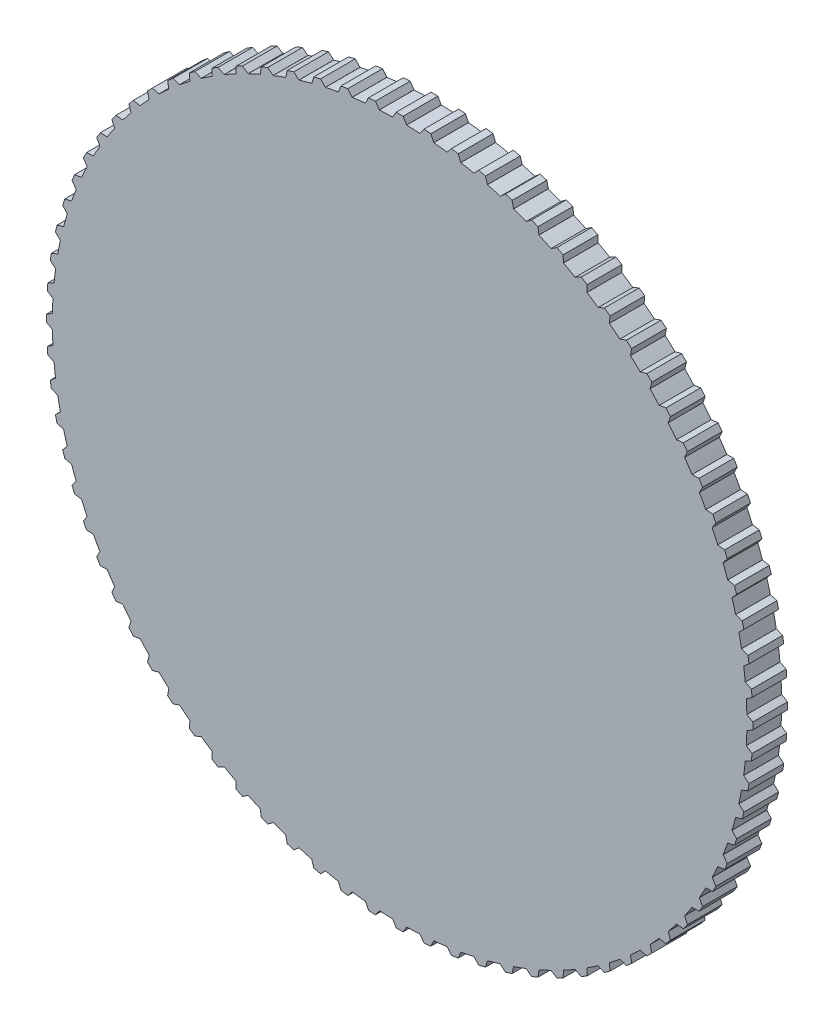
from build123d import *

# Parameters (mm, degrees)
BOSS_EXTRUDE1_DEPTH = 10


with BuildPart() as part:
    # Sketch1 → Boss-Extrude1 (new body)
    with BuildSketch(Plane.XY):
        with BuildLine():
            Line((0, 101.7), (1, 101.7))
            Line((1, 101.7), (2, 100))
            Line((2, 100), (1.99960012, 99.980005998))
            ThreePointArc((1.99960012, 99.980005998), (3.925981576, 99.922903624), (5.850904841, 99.828687823))
            Line((5.850904841, 99.828687823), (5.852074905, 99.848651565))
            Line((5.852074905, 99.848651565), (6.982372702, 101.464951936))
            Line((6.982372702, 101.464951936), (7.979290036, 101.386492841))
            Line((7.979290036, 101.386492841), (8.976207369, 101.308033745))
            Line((8.976207369, 101.308033745), (9.83974424, 99.534815182))
            Line((9.83974424, 99.534815182), (9.837776882, 99.514914189))
            ThreePointArc((9.837776882, 99.514914189), (11.753739746, 99.306845695), (13.665337029, 99.061892592))
            Line((13.665337029, 99.061892592), (13.668069823, 99.08170299))
            Line((13.668069823, 99.08170299), (14.921696754, 100.604338704))
            Line((14.921696754, 100.604338704), (15.909385095, 100.447904239))
            Line((15.909385095, 100.447904239), (16.897073435, 100.291469773))
            Line((16.897073435, 100.291469773), (17.618823185, 98.455965129))
            Line((17.618823185, 98.455965129), (17.615300477, 98.436279842))
            ThreePointArc((17.615300477, 98.436279842), (19.509032202, 98.07852804), (21.395517869, 97.684347851))
            Line((21.395517869, 97.684347851), (21.399796545, 97.703882767))
            Line((21.399796545, 97.703882767), (22.769023584, 99.123466268))
            Line((22.769023584, 99.123466268), (23.741393504, 98.890020904))
            Line((23.741393504, 98.890020904), (24.713763425, 98.656575541))
            Line((24.713763425, 98.656575541), (25.289276226, 96.770101312))
            Line((25.289276226, 96.770101312), (25.284219888, 96.750753096))
            ThreePointArc((25.284219888, 96.750753096), (27.144044987, 96.245523645), (28.993788227, 95.704546623))
            Line((28.993788227, 95.704546623), (28.999586405, 95.723685618))
            Line((28.999586405, 95.723685618), (30.475971812, 97.031464702))
            Line((30.475971812, 97.031464702), (31.427028328, 96.722447707))
            Line((31.427028328, 96.722447707), (32.378084844, 96.413430713))
            Line((32.378084844, 96.413430713), (32.80381247, 94.487617641))
            Line((32.80381247, 94.487617641), (32.797253675, 94.468725785))
            ThreePointArc((32.797253675, 94.468725785), (34.611705708, 93.819133592), (36.413302239, 93.134695039))
            Line((36.413302239, 93.134695039), (36.420584171, 93.153320116))
            Line((36.420584171, 93.153320116), (37.995025539, 94.341231889))
            Line((37.995025539, 94.341231889), (38.918905072, 93.958548456))
            Line((38.918905072, 93.958548456), (39.842784604, 93.575865024))
            Line((39.842784604, 93.575865024), (40.116102302, 91.622586386))
            Line((40.116102302, 91.622586386), (40.108081487, 91.604267365))
            ThreePointArc((40.108081487, 91.604267365), (41.865973754, 90.814317383), (43.608316134, 89.99063709))
            Line((43.608316134, 89.99063709), (43.617036926, 90.008633418))
            Line((43.617036926, 90.008633418), (45.279827299, 91.06935401))
            Line((45.279827299, 91.06935401), (46.170833824, 90.61536351))
            Line((46.170833824, 90.61536351), (47.061840348, 90.16137301))
            Line((47.061840348, 90.16137301), (47.181063022, 88.192671419))
            Line((47.181063022, 88.192671419), (47.17162964, 88.175038175))
            ThreePointArc((47.17162964, 88.175038175), (48.86212415, 87.249600707), (50.534470259, 86.291756939))
            Line((50.534470259, 86.291756939), (50.544576143, 86.309013565))
            Line((50.544576143, 86.309013565), (52.285463867, 87.23600328))
            Line((52.285463867, 87.23600328), (53.138104032, 86.713504715))
            Line((53.138104032, 86.713504715), (53.990744196, 86.19100615))
            Line((53.990744196, 86.19100615), (53.9551368, 84.219019306))
            Line((53.9551368, 84.219019306), (53.944349009, 84.202180554))
            ThreePointArc((53.944349009, 84.202180554), (55.557023302, 83.14696123), (57.149062571, 82.060859411))
            Line((57.149062571, 82.060859411), (57.16049124, 82.077269942))
            Line((57.16049124, 82.077269942), (58.968743164, 82.86481358))
            Line((58.968743164, 82.86481358), (59.777760158, 82.277028328))
            Line((59.777760158, 82.277028328), (60.586777153, 81.689243076))
            Line((60.586777153, 81.689243076), (60.396559218, 79.726128933))
            Line((60.396559218, 79.726128933), (60.384483529, 79.710188489))
            ThreePointArc((60.384483529, 79.710188489), (61.909394931, 78.531693088), (63.411311907, 77.324029397))
            Line((63.411311907, 77.324029397), (63.423992902, 77.339492657))
            Line((63.423992902, 77.339492657), (65.28846055, 77.98273475))
            Line((65.28846055, 77.98273475), (66.048866515, 77.333286702))
            Line((66.048866515, 77.333286702), (66.809272481, 76.683838653))
            Line((66.809272481, 76.683838653), (66.465616764, 74.741700463))
            Line((66.465616764, 74.741700463), (66.452327627, 74.726756606))
            ThreePointArc((66.452327627, 74.726756606), (67.880074553, 73.432250944), (69.28260942, 72.110471029))
            Line((69.28260942, 72.110471029), (69.296464556, 72.124891681))
            Line((69.296464556, 72.124891681), (71.205652865, 72.619866428))
            Line((71.205652865, 72.619866428), (71.912759647, 71.912759647))
            Line((71.912759647, 71.912759647), (72.619866428, 71.205652865))
            Line((72.619866428, 71.205652865), (72.124891681, 69.296464556))
            Line((72.124891681, 69.296464556), (72.110471029, 69.28260942))
            ThreePointArc((72.110471029, 69.28260942), (73.432250944, 67.880074553), (74.726756606, 66.452327627))
            Line((74.726756606, 66.452327627), (74.741700463, 66.465616764))
            Line((74.741700463, 66.465616764), (76.683838653, 66.809272481))
            Line((76.683838653, 66.809272481), (77.333286702, 66.048866515))
            Line((77.333286702, 66.048866515), (77.98273475, 65.28846055))
            Line((77.98273475, 65.28846055), (77.339492657, 63.423992902))
            Line((77.339492657, 63.423992902), (77.324029397, 63.411311907))
            ThreePointArc((77.324029397, 63.411311907), (78.531693088, 61.909394931), (79.710188489, 60.384483529))
            Line((79.710188489, 60.384483529), (79.726128933, 60.396559218))
            Line((79.726128933, 60.396559218), (81.689243076, 60.586777153))
            Line((81.689243076, 60.586777153), (82.277028328, 59.777760158))
            Line((82.277028328, 59.777760158), (82.86481358, 58.968743164))
            Line((82.86481358, 58.968743164), (82.077269942, 57.160491241))
            Line((82.077269942, 57.160491241), (82.060859411, 57.149062571))
            ThreePointArc((82.060859411, 57.149062571), (83.14696123, 55.557023302), (84.202180554, 53.944349009))
            Line((84.202180554, 53.944349009), (84.219019306, 53.9551368))
            Line((84.219019306, 53.9551368), (86.19100615, 53.990744196))
            Line((86.19100615, 53.990744196), (86.713504715, 53.138104032))
            Line((86.713504715, 53.138104032), (87.23600328, 52.285463867))
            Line((87.23600328, 52.285463867), (86.309013565, 50.544576143))
            Line((86.309013565, 50.544576143), (86.291756939, 50.534470259))
            ThreePointArc((86.291756939, 50.534470259), (87.249600707, 48.86212415), (88.175038175, 47.17162964))
            Line((88.175038175, 47.17162964), (88.192671419, 47.181063022))
            Line((88.192671419, 47.181063022), (90.16137301, 47.061840348))
            Line((90.16137301, 47.061840348), (90.61536351, 46.170833824))
            Line((90.61536351, 46.170833824), (91.06935401, 45.279827299))
            Line((91.06935401, 45.279827299), (90.008633418, 43.617036926))
            Line((90.008633418, 43.617036926), (89.99063709, 43.608316134))
            ThreePointArc((89.99063709, 43.608316134), (90.814317383, 41.865973754), (91.604267365, 40.108081487))
            Line((91.604267365, 40.108081487), (91.622586386, 40.116102302))
            Line((91.622586386, 40.116102302), (93.575865024, 39.842784604))
            Line((93.575865024, 39.842784604), (93.958548456, 38.918905072))
            Line((93.958548456, 38.918905072), (94.341231889, 37.995025539))
            Line((94.341231889, 37.995025539), (93.153320116, 36.420584171))
            Line((93.153320116, 36.420584171), (93.134695039, 36.413302239))
            ThreePointArc((93.134695039, 36.413302239), (93.819133592, 34.611705708), (94.468725785, 32.797253675))
            Line((94.468725785, 32.797253675), (94.487617641, 32.80381247))
            Line((94.487617641, 32.80381247), (96.413430713, 32.378084844))
            Line((96.413430713, 32.378084844), (96.722447707, 31.427028328))
            Line((96.722447707, 31.427028328), (97.031464702, 30.475971812))
            Line((97.031464702, 30.475971812), (95.723685618, 28.999586405))
            Line((95.723685618, 28.999586405), (95.704546623, 28.993788227))
            ThreePointArc((95.704546623, 28.993788227), (96.245523645, 27.144044987), (96.750753096, 25.284219888))
            Line((96.750753096, 25.284219888), (96.770101312, 25.289276226))
            Line((96.770101312, 25.289276226), (98.656575541, 24.713763425))
            Line((98.656575541, 24.713763425), (98.890020904, 23.741393504))
            Line((98.890020904, 23.741393504), (99.123466268, 22.769023584))
            Line((99.123466268, 22.769023584), (97.703882767, 21.399796545))
            Line((97.703882767, 21.399796545), (97.684347851, 21.395517869))
            ThreePointArc((97.684347851, 21.395517869), (98.07852804, 19.509032202), (98.436279842, 17.615300477))
            Line((98.436279842, 17.615300477), (98.455965129, 17.618823185))
            Line((98.455965129, 17.618823185), (100.291469773, 16.897073435))
            Line((100.291469773, 16.897073435), (100.447904239, 15.909385095))
            Line((100.447904239, 15.909385095), (100.604338704, 14.921696754))
            Line((100.604338704, 14.921696754), (99.08170299, 13.668069823))
            Line((99.08170299, 13.668069823), (99.061892592, 13.665337029))
            ThreePointArc((99.061892592, 13.665337029), (99.306845695, 11.753739746), (99.514914189, 9.837776882))
            Line((99.514914189, 9.837776882), (99.534815182, 9.83974424))
            Line((99.534815182, 9.83974424), (101.308033745, 8.976207369))
            Line((101.308033745, 8.976207369), (101.386492841, 7.979290036))
            Line((101.386492841, 7.979290036), (101.464951936, 6.982372702))
            Line((101.464951936, 6.982372702), (99.848651565, 5.852074905))
            Line((99.848651565, 5.852074905), (99.828687823, 5.850904841))
            ThreePointArc((99.828687823, 5.850904841), (99.922903624, 3.925981576), (99.980005998, 1.99960012))
            Line((99.980005998, 1.99960012), (100, 2))
            Line((100, 2), (101.7, 1))
            Line((101.7, 1), (101.7, 0))
            Line((101.7, 0), (101.7, -1))
            Line((101.7, -1), (100, -2))
            Line((100, -2), (99.980005998, -1.99960012))
            ThreePointArc((99.980005998, -1.99960012), (99.922903624, -3.925981576), (99.828687823, -5.850904841))
            Line((99.828687823, -5.850904841), (99.848651565, -5.852074905))
            Line((99.848651565, -5.852074905), (101.464951936, -6.982372702))
            Line((101.464951936, -6.982372702), (101.386492841, -7.979290036))
            Line((101.386492841, -7.979290036), (101.308033745, -8.976207369))
            Line((101.308033745, -8.976207369), (99.534815182, -9.83974424))
            Line((99.534815182, -9.83974424), (99.514914189, -9.837776882))
            ThreePointArc((99.514914189, -9.837776882), (99.306845695, -11.753739746), (99.061892592, -13.665337029))
            Line((99.061892592, -13.665337029), (99.08170299, -13.668069823))
            Line((99.08170299, -13.668069823), (100.604338704, -14.921696754))
            Line((100.604338704, -14.921696754), (100.447904239, -15.909385095))
            Line((100.447904239, -15.909385095), (100.291469773, -16.897073435))
            Line((100.291469773, -16.897073435), (98.455965129, -17.618823185))
            Line((98.455965129, -17.618823185), (98.436279842, -17.615300477))
            ThreePointArc((98.436279842, -17.615300477), (98.07852804, -19.509032202), (97.684347851, -21.395517869))
            Line((97.684347851, -21.395517869), (97.703882767, -21.399796545))
            Line((97.703882767, -21.399796545), (99.123466268, -22.769023584))
            Line((99.123466268, -22.769023584), (98.890020904, -23.741393504))
            Line((98.890020904, -23.741393504), (98.656575541, -24.713763425))
            Line((98.656575541, -24.713763425), (96.770101312, -25.289276226))
            Line((96.770101312, -25.289276226), (96.750753096, -25.284219888))
            ThreePointArc((96.750753096, -25.284219888), (96.245523645, -27.144044987), (95.704546623, -28.993788227))
            Line((95.704546623, -28.993788227), (95.723685618, -28.999586405))
            Line((95.723685618, -28.999586405), (97.031464702, -30.475971812))
            Line((97.031464702, -30.475971812), (96.722447707, -31.427028328))
            Line((96.722447707, -31.427028328), (96.413430713, -32.378084844))
            Line((96.413430713, -32.378084844), (94.487617641, -32.80381247))
            Line((94.487617641, -32.80381247), (94.468725785, -32.797253675))
            ThreePointArc((94.468725785, -32.797253675), (93.819133592, -34.611705708), (93.134695039, -36.413302239))
            Line((93.134695039, -36.413302239), (93.153320116, -36.420584171))
            Line((93.153320116, -36.420584171), (94.341231889, -37.995025539))
            Line((94.341231889, -37.995025539), (93.958548456, -38.918905072))
            Line((93.958548456, -38.918905072), (93.575865024, -39.842784604))
            Line((93.575865024, -39.842784604), (91.622586386, -40.116102302))
            Line((91.622586386, -40.116102302), (91.604267365, -40.108081487))
            ThreePointArc((91.604267365, -40.108081487), (90.814317383, -41.865973754), (89.99063709, -43.608316134))
            Line((89.99063709, -43.608316134), (90.008633418, -43.617036926))
            Line((90.008633418, -43.617036926), (91.06935401, -45.279827299))
            Line((91.06935401, -45.279827299), (90.61536351, -46.170833824))
            Line((90.61536351, -46.170833824), (90.16137301, -47.061840348))
            Line((90.16137301, -47.061840348), (88.192671419, -47.181063022))
            Line((88.192671419, -47.181063022), (88.175038175, -47.17162964))
            ThreePointArc((88.175038175, -47.17162964), (87.249600707, -48.86212415), (86.291756939, -50.534470259))
            Line((86.291756939, -50.534470259), (86.309013565, -50.544576143))
            Line((86.309013565, -50.544576143), (87.23600328, -52.285463867))
            Line((87.23600328, -52.285463867), (86.713504715, -53.138104032))
            Line((86.713504715, -53.138104032), (86.19100615, -53.990744196))
            Line((86.19100615, -53.990744196), (84.219019306, -53.9551368))
            Line((84.219019306, -53.9551368), (84.202180554, -53.944349009))
            ThreePointArc((84.202180554, -53.944349009), (83.14696123, -55.557023302), (82.060859411, -57.149062571))
            Line((82.060859411, -57.149062571), (82.077269942, -57.16049124))
            Line((82.077269942, -57.16049124), (82.86481358, -58.968743164))
            Line((82.86481358, -58.968743164), (82.277028328, -59.777760158))
            Line((82.277028328, -59.777760158), (81.689243076, -60.586777153))
            Line((81.689243076, -60.586777153), (79.726128933, -60.396559218))
            Line((79.726128933, -60.396559218), (79.710188489, -60.384483529))
            ThreePointArc((79.710188489, -60.384483529), (78.531693088, -61.909394931), (77.324029397, -63.411311907))
            Line((77.324029397, -63.411311907), (77.339492657, -63.423992902))
            Line((77.339492657, -63.423992902), (77.98273475, -65.28846055))
            Line((77.98273475, -65.28846055), (77.333286702, -66.048866515))
            Line((77.333286702, -66.048866515), (76.683838653, -66.809272481))
            Line((76.683838653, -66.809272481), (74.741700463, -66.465616764))
            Line((74.741700463, -66.465616764), (74.726756606, -66.452327627))
            ThreePointArc((74.726756606, -66.452327627), (73.432250944, -67.880074553), (72.110471029, -69.28260942))
            Line((72.110471029, -69.28260942), (72.124891681, -69.296464556))
            Line((72.124891681, -69.296464556), (72.619866428, -71.205652865))
            Line((72.619866428, -71.205652865), (71.912759647, -71.912759647))
            Line((71.912759647, -71.912759647), (71.205652865, -72.619866428))
            Line((71.205652865, -72.619866428), (69.296464556, -72.124891681))
            Line((69.296464556, -72.124891681), (69.28260942, -72.110471029))
            ThreePointArc((69.28260942, -72.110471029), (67.880074553, -73.432250944), (66.452327627, -74.726756606))
            Line((66.452327627, -74.726756606), (66.465616764, -74.741700463))
            Line((66.465616764, -74.741700463), (66.809272481, -76.683838653))
            Line((66.809272481, -76.683838653), (66.048866515, -77.333286702))
            Line((66.048866515, -77.333286702), (65.28846055, -77.98273475))
            Line((65.28846055, -77.98273475), (63.423992902, -77.339492657))
            Line((63.423992902, -77.339492657), (63.411311907, -77.324029397))
            ThreePointArc((63.411311907, -77.324029397), (61.909394931, -78.531693088), (60.384483529, -79.710188489))
            Line((60.384483529, -79.710188489), (60.396559218, -79.726128933))
            Line((60.396559218, -79.726128933), (60.586777153, -81.689243076))
            Line((60.586777153, -81.689243076), (59.777760158, -82.277028328))
            Line((59.777760158, -82.277028328), (58.968743164, -82.86481358))
            Line((58.968743164, -82.86481358), (57.16049124, -82.077269942))
            Line((57.16049124, -82.077269942), (57.149062571, -82.060859411))
            ThreePointArc((57.149062571, -82.060859411), (55.557023302, -83.14696123), (53.944349009, -84.202180554))
            Line((53.944349009, -84.202180554), (53.9551368, -84.219019306))
            Line((53.9551368, -84.219019306), (53.990744196, -86.19100615))
            Line((53.990744196, -86.19100615), (53.138104032, -86.713504715))
            Line((53.138104032, -86.713504715), (52.285463867, -87.23600328))
            Line((52.285463867, -87.23600328), (50.544576143, -86.309013565))
            Line((50.544576143, -86.309013565), (50.534470259, -86.291756939))
            ThreePointArc((50.534470259, -86.291756939), (48.86212415, -87.249600707), (47.17162964, -88.175038175))
            Line((47.17162964, -88.175038175), (47.181063022, -88.192671419))
            Line((47.181063022, -88.192671419), (47.061840348, -90.16137301))
            Line((47.061840348, -90.16137301), (46.170833824, -90.61536351))
            Line((46.170833824, -90.61536351), (45.279827299, -91.06935401))
            Line((45.279827299, -91.06935401), (43.617036926, -90.008633418))
            Line((43.617036926, -90.008633418), (43.608316134, -89.99063709))
            ThreePointArc((43.608316134, -89.99063709), (41.865973754, -90.814317383), (40.108081487, -91.604267365))
            Line((40.108081487, -91.604267365), (40.116102302, -91.622586386))
            Line((40.116102302, -91.622586386), (39.842784604, -93.575865024))
            Line((39.842784604, -93.575865024), (38.918905072, -93.958548456))
            Line((38.918905072, -93.958548456), (37.995025539, -94.341231889))
            Line((37.995025539, -94.341231889), (36.420584171, -93.153320116))
            Line((36.420584171, -93.153320116), (36.413302239, -93.134695039))
            ThreePointArc((36.413302239, -93.134695039), (34.611705708, -93.819133592), (32.797253675, -94.468725785))
            Line((32.797253675, -94.468725785), (32.80381247, -94.487617641))
            Line((32.80381247, -94.487617641), (32.378084844, -96.413430713))
            Line((32.378084844, -96.413430713), (31.427028328, -96.722447707))
            Line((31.427028328, -96.722447707), (30.475971812, -97.031464702))
            Line((30.475971812, -97.031464702), (28.999586405, -95.723685618))
            Line((28.999586405, -95.723685618), (28.993788227, -95.704546623))
            ThreePointArc((28.993788227, -95.704546623), (27.144044987, -96.245523645), (25.284219888, -96.750753096))
            Line((25.284219888, -96.750753096), (25.289276226, -96.770101312))
            Line((25.289276226, -96.770101312), (24.713763425, -98.656575541))
            Line((24.713763425, -98.656575541), (23.741393504, -98.890020904))
            Line((23.741393504, -98.890020904), (22.769023584, -99.123466268))
            Line((22.769023584, -99.123466268), (21.399796545, -97.703882767))
            Line((21.399796545, -97.703882767), (21.395517869, -97.684347851))
            ThreePointArc((21.395517869, -97.684347851), (19.509032202, -98.07852804), (17.615300477, -98.436279842))
            Line((17.615300477, -98.436279842), (17.618823185, -98.455965129))
            Line((17.618823185, -98.455965129), (16.897073435, -100.291469773))
            Line((16.897073435, -100.291469773), (15.909385095, -100.447904239))
            Line((15.909385095, -100.447904239), (14.921696754, -100.604338704))
            Line((14.921696754, -100.604338704), (13.668069823, -99.08170299))
            Line((13.668069823, -99.08170299), (13.665337029, -99.061892592))
            ThreePointArc((13.665337029, -99.061892592), (11.753739746, -99.306845695), (9.837776882, -99.514914189))
            Line((9.837776882, -99.514914189), (9.83974424, -99.534815182))
            Line((9.83974424, -99.534815182), (8.976207369, -101.308033745))
            Line((8.976207369, -101.308033745), (7.979290036, -101.386492841))
            Line((7.979290036, -101.386492841), (6.982372702, -101.464951936))
            Line((6.982372702, -101.464951936), (5.852074905, -99.848651565))
            Line((5.852074905, -99.848651565), (5.850904841, -99.828687823))
            ThreePointArc((5.850904841, -99.828687823), (3.925981576, -99.922903624), (1.99960012, -99.980005998))
            Line((1.99960012, -99.980005998), (2, -100))
            Line((2, -100), (1, -101.7))
            Line((1, -101.7), (0, -101.7))
            Line((0, -101.7), (-1, -101.7))
            Line((-1, -101.7), (-2, -100))
            Line((-2, -100), (-1.99960012, -99.980005998))
            ThreePointArc((-1.99960012, -99.980005998), (-3.925981576, -99.922903624), (-5.850904841, -99.828687823))
            Line((-5.850904841, -99.828687823), (-5.852074905, -99.848651565))
            Line((-5.852074905, -99.848651565), (-6.982372702, -101.464951936))
            Line((-6.982372702, -101.464951936), (-7.979290036, -101.386492841))
            Line((-7.979290036, -101.386492841), (-8.976207369, -101.308033745))
            Line((-8.976207369, -101.308033745), (-9.83974424, -99.534815182))
            Line((-9.83974424, -99.534815182), (-9.837776882, -99.514914189))
            ThreePointArc((-9.837776882, -99.514914189), (-11.753739746, -99.306845695), (-13.665337029, -99.061892592))
            Line((-13.665337029, -99.061892592), (-13.668069823, -99.08170299))
            Line((-13.668069823, -99.08170299), (-14.921696754, -100.604338704))
            Line((-14.921696754, -100.604338704), (-15.909385095, -100.447904239))
            Line((-15.909385095, -100.447904239), (-16.897073435, -100.291469773))
            Line((-16.897073435, -100.291469773), (-17.618823185, -98.455965129))
            Line((-17.618823185, -98.455965129), (-17.615300477, -98.436279842))
            ThreePointArc((-17.615300477, -98.436279842), (-19.509032202, -98.07852804), (-21.395517869, -97.684347851))
            Line((-21.395517869, -97.684347851), (-21.399796545, -97.703882767))
            Line((-21.399796545, -97.703882767), (-22.769023584, -99.123466268))
            Line((-22.769023584, -99.123466268), (-23.741393504, -98.890020904))
            Line((-23.741393504, -98.890020904), (-24.713763425, -98.656575541))
            Line((-24.713763425, -98.656575541), (-25.289276226, -96.770101312))
            Line((-25.289276226, -96.770101312), (-25.284219888, -96.750753096))
            ThreePointArc((-25.284219888, -96.750753096), (-27.144044987, -96.245523645), (-28.993788227, -95.704546623))
            Line((-28.993788227, -95.704546623), (-28.999586405, -95.723685618))
            Line((-28.999586405, -95.723685618), (-30.475971812, -97.031464702))
            Line((-30.475971812, -97.031464702), (-31.427028328, -96.722447707))
            Line((-31.427028328, -96.722447707), (-32.378084844, -96.413430713))
            Line((-32.378084844, -96.413430713), (-32.80381247, -94.487617641))
            Line((-32.80381247, -94.487617641), (-32.797253675, -94.468725785))
            ThreePointArc((-32.797253675, -94.468725785), (-34.611705708, -93.819133592), (-36.413302239, -93.134695039))
            Line((-36.413302239, -93.134695039), (-36.420584171, -93.153320116))
            Line((-36.420584171, -93.153320116), (-37.995025539, -94.341231889))
            Line((-37.995025539, -94.341231889), (-38.918905072, -93.958548456))
            Line((-38.918905072, -93.958548456), (-39.842784604, -93.575865024))
            Line((-39.842784604, -93.575865024), (-40.116102302, -91.622586386))
            Line((-40.116102302, -91.622586386), (-40.108081487, -91.604267365))
            ThreePointArc((-40.108081487, -91.604267365), (-41.865973754, -90.814317383), (-43.608316134, -89.99063709))
            Line((-43.608316134, -89.99063709), (-43.617036926, -90.008633418))
            Line((-43.617036926, -90.008633418), (-45.279827299, -91.06935401))
            Line((-45.279827299, -91.06935401), (-46.170833824, -90.61536351))
            Line((-46.170833824, -90.61536351), (-47.061840348, -90.16137301))
            Line((-47.061840348, -90.16137301), (-47.181063022, -88.192671419))
            Line((-47.181063022, -88.192671419), (-47.17162964, -88.175038175))
            ThreePointArc((-47.17162964, -88.175038175), (-48.86212415, -87.249600707), (-50.534470259, -86.291756939))
            Line((-50.534470259, -86.291756939), (-50.544576143, -86.309013565))
            Line((-50.544576143, -86.309013565), (-52.285463867, -87.23600328))
            Line((-52.285463867, -87.23600328), (-53.138104032, -86.713504715))
            Line((-53.138104032, -86.713504715), (-53.990744196, -86.19100615))
            Line((-53.990744196, -86.19100615), (-53.9551368, -84.219019306))
            Line((-53.9551368, -84.219019306), (-53.944349009, -84.202180554))
            ThreePointArc((-53.944349009, -84.202180554), (-55.557023302, -83.14696123), (-57.149062571, -82.060859411))
            Line((-57.149062571, -82.060859411), (-57.16049124, -82.077269942))
            Line((-57.16049124, -82.077269942), (-58.968743164, -82.86481358))
            Line((-58.968743164, -82.86481358), (-59.777760158, -82.277028328))
            Line((-59.777760158, -82.277028328), (-60.586777153, -81.689243076))
            Line((-60.586777153, -81.689243076), (-60.396559218, -79.726128933))
            Line((-60.396559218, -79.726128933), (-60.384483529, -79.710188489))
            ThreePointArc((-60.384483529, -79.710188489), (-61.909394931, -78.531693088), (-63.411311907, -77.324029397))
            Line((-63.411311907, -77.324029397), (-63.423992902, -77.339492657))
            Line((-63.423992902, -77.339492657), (-65.28846055, -77.98273475))
            Line((-65.28846055, -77.98273475), (-66.048866515, -77.333286702))
            Line((-66.048866515, -77.333286702), (-66.809272481, -76.683838653))
            Line((-66.809272481, -76.683838653), (-66.465616764, -74.741700463))
            Line((-66.465616764, -74.741700463), (-66.452327627, -74.726756606))
            ThreePointArc((-66.452327627, -74.726756606), (-67.880074553, -73.432250944), (-69.28260942, -72.110471029))
            Line((-69.28260942, -72.110471029), (-69.296464556, -72.124891681))
            Line((-69.296464556, -72.124891681), (-71.205652865, -72.619866428))
            Line((-71.205652865, -72.619866428), (-71.912759647, -71.912759647))
            Line((-71.912759647, -71.912759647), (-72.619866428, -71.205652865))
            Line((-72.619866428, -71.205652865), (-72.124891681, -69.296464556))
            Line((-72.124891681, -69.296464556), (-72.110471029, -69.28260942))
            ThreePointArc((-72.110471029, -69.28260942), (-73.432250944, -67.880074553), (-74.726756606, -66.452327627))
            Line((-74.726756606, -66.452327627), (-74.741700463, -66.465616764))
            Line((-74.741700463, -66.465616764), (-76.683838653, -66.809272481))
            Line((-76.683838653, -66.809272481), (-77.333286702, -66.048866515))
            Line((-77.333286702, -66.048866515), (-77.98273475, -65.28846055))
            Line((-77.98273475, -65.28846055), (-77.339492657, -63.423992902))
            Line((-77.339492657, -63.423992902), (-77.324029397, -63.411311907))
            ThreePointArc((-77.324029397, -63.411311907), (-78.531693088, -61.909394931), (-79.710188489, -60.384483529))
            Line((-79.710188489, -60.384483529), (-79.726128933, -60.396559218))
            Line((-79.726128933, -60.396559218), (-81.689243076, -60.586777153))
            Line((-81.689243076, -60.586777153), (-82.277028328, -59.777760158))
            Line((-82.277028328, -59.777760158), (-82.86481358, -58.968743164))
            Line((-82.86481358, -58.968743164), (-82.077269942, -57.16049124))
            Line((-82.077269942, -57.16049124), (-82.060859411, -57.149062571))
            ThreePointArc((-82.060859411, -57.149062571), (-83.14696123, -55.557023302), (-84.202180554, -53.944349009))
            Line((-84.202180554, -53.944349009), (-84.219019306, -53.9551368))
            Line((-84.219019306, -53.9551368), (-86.19100615, -53.990744196))
            Line((-86.19100615, -53.990744196), (-86.713504715, -53.138104032))
            Line((-86.713504715, -53.138104032), (-87.23600328, -52.285463867))
            Line((-87.23600328, -52.285463867), (-86.309013565, -50.544576143))
            Line((-86.309013565, -50.544576143), (-86.291756939, -50.534470259))
            ThreePointArc((-86.291756939, -50.534470259), (-87.249600707, -48.86212415), (-88.175038175, -47.17162964))
            Line((-88.175038175, -47.17162964), (-88.192671419, -47.181063022))
            Line((-88.192671419, -47.181063022), (-90.16137301, -47.061840348))
            Line((-90.16137301, -47.061840348), (-90.61536351, -46.170833824))
            Line((-90.61536351, -46.170833824), (-91.06935401, -45.279827299))
            Line((-91.06935401, -45.279827299), (-90.008633418, -43.617036926))
            Line((-90.008633418, -43.617036926), (-89.99063709, -43.608316134))
            ThreePointArc((-89.99063709, -43.608316134), (-90.814317383, -41.865973754), (-91.604267365, -40.108081487))
            Line((-91.604267365, -40.108081487), (-91.622586386, -40.116102302))
            Line((-91.622586386, -40.116102302), (-93.575865024, -39.842784604))
            Line((-93.575865024, -39.842784604), (-93.958548456, -38.918905072))
            Line((-93.958548456, -38.918905072), (-94.341231889, -37.995025539))
            Line((-94.341231889, -37.995025539), (-93.153320116, -36.420584171))
            Line((-93.153320116, -36.420584171), (-93.134695039, -36.413302239))
            ThreePointArc((-93.134695039, -36.413302239), (-93.819133592, -34.611705708), (-94.468725785, -32.797253675))
            Line((-94.468725785, -32.797253675), (-94.487617641, -32.80381247))
            Line((-94.487617641, -32.80381247), (-96.413430713, -32.378084844))
            Line((-96.413430713, -32.378084844), (-96.722447707, -31.427028328))
            Line((-96.722447707, -31.427028328), (-97.031464702, -30.475971812))
            Line((-97.031464702, -30.475971812), (-95.723685618, -28.999586405))
            Line((-95.723685618, -28.999586405), (-95.704546623, -28.993788227))
            ThreePointArc((-95.704546623, -28.993788227), (-96.245523645, -27.144044987), (-96.750753096, -25.284219888))
            Line((-96.750753096, -25.284219888), (-96.770101312, -25.289276226))
            Line((-96.770101312, -25.289276226), (-98.656575541, -24.713763425))
            Line((-98.656575541, -24.713763425), (-98.890020904, -23.741393504))
            Line((-98.890020904, -23.741393504), (-99.123466268, -22.769023584))
            Line((-99.123466268, -22.769023584), (-97.703882767, -21.399796545))
            Line((-97.703882767, -21.399796545), (-97.684347851, -21.395517869))
            ThreePointArc((-97.684347851, -21.395517869), (-98.07852804, -19.509032202), (-98.436279842, -17.615300477))
            Line((-98.436279842, -17.615300477), (-98.455965129, -17.618823185))
            Line((-98.455965129, -17.618823185), (-100.291469773, -16.897073435))
            Line((-100.291469773, -16.897073435), (-100.447904239, -15.909385095))
            Line((-100.447904239, -15.909385095), (-100.604338704, -14.921696754))
            Line((-100.604338704, -14.921696754), (-99.08170299, -13.668069823))
            Line((-99.08170299, -13.668069823), (-99.061892592, -13.665337029))
            ThreePointArc((-99.061892592, -13.665337029), (-99.306845695, -11.753739746), (-99.514914189, -9.837776882))
            Line((-99.514914189, -9.837776882), (-99.534815182, -9.83974424))
            Line((-99.534815182, -9.83974424), (-101.308033745, -8.976207369))
            Line((-101.308033745, -8.976207369), (-101.386492841, -7.979290036))
            Line((-101.386492841, -7.979290036), (-101.464951936, -6.982372702))
            Line((-101.464951936, -6.982372702), (-99.848651565, -5.852074905))
            Line((-99.848651565, -5.852074905), (-99.828687823, -5.850904841))
            ThreePointArc((-99.828687823, -5.850904841), (-99.922903624, -3.925981576), (-99.980005998, -1.99960012))
            Line((-99.980005998, -1.99960012), (-100, -2))
            Line((-100, -2), (-101.7, -1))
            Line((-101.7, -1), (-101.7, 0))
            Line((-101.7, 0), (-101.7, 1))
            Line((-101.7, 1), (-100, 2))
            Line((-100, 2), (-99.980005998, 1.99960012))
            ThreePointArc((-99.980005998, 1.99960012), (-99.922903624, 3.925981576), (-99.828687823, 5.850904841))
            Line((-99.828687823, 5.850904841), (-99.848651565, 5.852074905))
            Line((-99.848651565, 5.852074905), (-101.464951936, 6.982372702))
            Line((-101.464951936, 6.982372702), (-101.386492841, 7.979290036))
            Line((-101.386492841, 7.979290036), (-101.308033745, 8.976207369))
            Line((-101.308033745, 8.976207369), (-99.534815182, 9.83974424))
            Line((-99.534815182, 9.83974424), (-99.514914189, 9.837776882))
            ThreePointArc((-99.514914189, 9.837776882), (-99.306845695, 11.753739746), (-99.061892592, 13.665337029))
            Line((-99.061892592, 13.665337029), (-99.08170299, 13.668069823))
            Line((-99.08170299, 13.668069823), (-100.604338704, 14.921696754))
            Line((-100.604338704, 14.921696754), (-100.447904239, 15.909385095))
            Line((-100.447904239, 15.909385095), (-100.291469773, 16.897073435))
            Line((-100.291469773, 16.897073435), (-98.455965129, 17.618823185))
            Line((-98.455965129, 17.618823185), (-98.436279842, 17.615300477))
            ThreePointArc((-98.436279842, 17.615300477), (-98.07852804, 19.509032202), (-97.684347851, 21.395517869))
            Line((-97.684347851, 21.395517869), (-97.703882767, 21.399796545))
            Line((-97.703882767, 21.399796545), (-99.123466268, 22.769023584))
            Line((-99.123466268, 22.769023584), (-98.890020904, 23.741393504))
            Line((-98.890020904, 23.741393504), (-98.656575541, 24.713763425))
            Line((-98.656575541, 24.713763425), (-96.770101312, 25.289276226))
            Line((-96.770101312, 25.289276226), (-96.750753096, 25.284219888))
            ThreePointArc((-96.750753096, 25.284219888), (-96.245523645, 27.144044987), (-95.704546623, 28.993788227))
            Line((-95.704546623, 28.993788227), (-95.723685618, 28.999586405))
            Line((-95.723685618, 28.999586405), (-97.031464702, 30.475971812))
            Line((-97.031464702, 30.475971812), (-96.722447707, 31.427028328))
            Line((-96.722447707, 31.427028328), (-96.413430713, 32.378084844))
            Line((-96.413430713, 32.378084844), (-94.487617641, 32.80381247))
            Line((-94.487617641, 32.80381247), (-94.468725785, 32.797253675))
            ThreePointArc((-94.468725785, 32.797253675), (-93.819133592, 34.611705708), (-93.134695039, 36.413302239))
            Line((-93.134695039, 36.413302239), (-93.153320116, 36.420584171))
            Line((-93.153320116, 36.420584171), (-94.341231889, 37.995025539))
            Line((-94.341231889, 37.995025539), (-93.958548456, 38.918905072))
            Line((-93.958548456, 38.918905072), (-93.575865024, 39.842784604))
            Line((-93.575865024, 39.842784604), (-91.622586386, 40.116102302))
            Line((-91.622586386, 40.116102302), (-91.604267365, 40.108081487))
            ThreePointArc((-91.604267365, 40.108081487), (-90.814317383, 41.865973754), (-89.99063709, 43.608316134))
            Line((-89.99063709, 43.608316134), (-90.008633418, 43.617036926))
            Line((-90.008633418, 43.617036926), (-91.06935401, 45.279827299))
            Line((-91.06935401, 45.279827299), (-90.61536351, 46.170833824))
            Line((-90.61536351, 46.170833824), (-90.16137301, 47.061840348))
            Line((-90.16137301, 47.061840348), (-88.192671419, 47.181063022))
            Line((-88.192671419, 47.181063022), (-88.175038175, 47.17162964))
            ThreePointArc((-88.175038175, 47.17162964), (-87.249600707, 48.86212415), (-86.291756939, 50.534470259))
            Line((-86.291756939, 50.534470259), (-86.309013565, 50.544576143))
            Line((-86.309013565, 50.544576143), (-87.23600328, 52.285463867))
            Line((-87.23600328, 52.285463867), (-86.713504715, 53.138104032))
            Line((-86.713504715, 53.138104032), (-86.19100615, 53.990744196))
            Line((-86.19100615, 53.990744196), (-84.219019306, 53.9551368))
            Line((-84.219019306, 53.9551368), (-84.202180554, 53.944349009))
            ThreePointArc((-84.202180554, 53.944349009), (-83.14696123, 55.557023302), (-82.060859411, 57.149062571))
            Line((-82.060859411, 57.149062571), (-82.077269942, 57.16049124))
            Line((-82.077269942, 57.16049124), (-82.86481358, 58.968743164))
            Line((-82.86481358, 58.968743164), (-82.277028328, 59.777760158))
            Line((-82.277028328, 59.777760158), (-81.689243076, 60.586777153))
            Line((-81.689243076, 60.586777153), (-79.726128933, 60.396559218))
            Line((-79.726128933, 60.396559218), (-79.710188489, 60.384483529))
            ThreePointArc((-79.710188489, 60.384483529), (-78.531693088, 61.909394931), (-77.324029397, 63.411311907))
            Line((-77.324029397, 63.411311907), (-77.339492657, 63.423992902))
            Line((-77.339492657, 63.423992902), (-77.98273475, 65.28846055))
            Line((-77.98273475, 65.28846055), (-77.333286702, 66.048866515))
            Line((-77.333286702, 66.048866515), (-76.683838653, 66.809272481))
            Line((-76.683838653, 66.809272481), (-74.741700463, 66.465616764))
            Line((-74.741700463, 66.465616764), (-74.726756606, 66.452327627))
            ThreePointArc((-74.726756606, 66.452327627), (-73.432250944, 67.880074553), (-72.110471029, 69.28260942))
            Line((-72.110471029, 69.28260942), (-72.124891681, 69.296464556))
            Line((-72.124891681, 69.296464556), (-72.619866428, 71.205652865))
            Line((-72.619866428, 71.205652865), (-71.912759647, 71.912759647))
            Line((-71.912759647, 71.912759647), (-71.205652865, 72.619866428))
            Line((-71.205652865, 72.619866428), (-69.296464556, 72.124891681))
            Line((-69.296464556, 72.124891681), (-69.28260942, 72.110471029))
            ThreePointArc((-69.28260942, 72.110471029), (-67.880074553, 73.432250944), (-66.452327627, 74.726756606))
            Line((-66.452327627, 74.726756606), (-66.465616764, 74.741700463))
            Line((-66.465616764, 74.741700463), (-66.809272481, 76.683838653))
            Line((-66.809272481, 76.683838653), (-66.048866515, 77.333286702))
            Line((-66.048866515, 77.333286702), (-65.28846055, 77.98273475))
            Line((-65.28846055, 77.98273475), (-63.423992902, 77.339492657))
            Line((-63.423992902, 77.339492657), (-63.411311907, 77.324029397))
            ThreePointArc((-63.411311907, 77.324029397), (-61.909394931, 78.531693088), (-60.384483529, 79.710188489))
            Line((-60.384483529, 79.710188489), (-60.396559218, 79.726128933))
            Line((-60.396559218, 79.726128933), (-60.586777153, 81.689243076))
            Line((-60.586777153, 81.689243076), (-59.777760158, 82.277028328))
            Line((-59.777760158, 82.277028328), (-58.968743164, 82.86481358))
            Line((-58.968743164, 82.86481358), (-57.16049124, 82.077269942))
            Line((-57.16049124, 82.077269942), (-57.149062571, 82.060859411))
            ThreePointArc((-57.149062571, 82.060859411), (-55.557023302, 83.14696123), (-53.944349009, 84.202180554))
            Line((-53.944349009, 84.202180554), (-53.9551368, 84.219019306))
            Line((-53.9551368, 84.219019306), (-53.990744196, 86.19100615))
            Line((-53.990744196, 86.19100615), (-53.138104032, 86.713504715))
            Line((-53.138104032, 86.713504715), (-52.285463867, 87.23600328))
            Line((-52.285463867, 87.23600328), (-50.544576143, 86.309013565))
            Line((-50.544576143, 86.309013565), (-50.534470259, 86.291756939))
            ThreePointArc((-50.534470259, 86.291756939), (-48.86212415, 87.249600707), (-47.17162964, 88.175038175))
            Line((-47.17162964, 88.175038175), (-47.181063022, 88.192671419))
            Line((-47.181063022, 88.192671419), (-47.061840348, 90.16137301))
            Line((-47.061840348, 90.16137301), (-46.170833824, 90.61536351))
            Line((-46.170833824, 90.61536351), (-45.279827299, 91.06935401))
            Line((-45.279827299, 91.06935401), (-43.617036926, 90.008633418))
            Line((-43.617036926, 90.008633418), (-43.608316134, 89.99063709))
            ThreePointArc((-43.608316134, 89.99063709), (-41.865973754, 90.814317383), (-40.108081487, 91.604267365))
            Line((-40.108081487, 91.604267365), (-40.116102302, 91.622586386))
            Line((-40.116102302, 91.622586386), (-39.842784604, 93.575865024))
            Line((-39.842784604, 93.575865024), (-38.918905072, 93.958548456))
            Line((-38.918905072, 93.958548456), (-37.995025539, 94.341231889))
            Line((-37.995025539, 94.341231889), (-36.420584171, 93.153320116))
            Line((-36.420584171, 93.153320116), (-36.413302239, 93.134695039))
            ThreePointArc((-36.413302239, 93.134695039), (-34.611705708, 93.819133592), (-32.797253675, 94.468725785))
            Line((-32.797253675, 94.468725785), (-32.80381247, 94.487617641))
            Line((-32.80381247, 94.487617641), (-32.378084844, 96.413430713))
            Line((-32.378084844, 96.413430713), (-31.427028328, 96.722447707))
            Line((-31.427028328, 96.722447707), (-30.475971812, 97.031464702))
            Line((-30.475971812, 97.031464702), (-28.999586405, 95.723685618))
            Line((-28.999586405, 95.723685618), (-28.993788227, 95.704546623))
            ThreePointArc((-28.993788227, 95.704546623), (-27.144044987, 96.245523645), (-25.284219888, 96.750753096))
            Line((-25.284219888, 96.750753096), (-25.289276226, 96.770101312))
            Line((-25.289276226, 96.770101312), (-24.713763425, 98.656575541))
            Line((-24.713763425, 98.656575541), (-23.741393504, 98.890020904))
            Line((-23.741393504, 98.890020904), (-22.769023584, 99.123466268))
            Line((-22.769023584, 99.123466268), (-21.399796545, 97.703882767))
            Line((-21.399796545, 97.703882767), (-21.395517869, 97.684347851))
            ThreePointArc((-21.395517869, 97.684347851), (-19.509032202, 98.07852804), (-17.615300477, 98.436279842))
            Line((-17.615300477, 98.436279842), (-17.618823185, 98.455965129))
            Line((-17.618823185, 98.455965129), (-16.897073435, 100.291469773))
            Line((-16.897073435, 100.291469773), (-15.909385095, 100.447904239))
            Line((-15.909385095, 100.447904239), (-14.921696754, 100.604338704))
            Line((-14.921696754, 100.604338704), (-13.668069823, 99.08170299))
            Line((-13.668069823, 99.08170299), (-13.665337029, 99.061892592))
            ThreePointArc((-13.665337029, 99.061892592), (-11.753739746, 99.306845695), (-9.837776882, 99.514914189))
            Line((-9.837776882, 99.514914189), (-9.83974424, 99.534815182))
            Line((-9.83974424, 99.534815182), (-8.976207369, 101.308033745))
            Line((-8.976207369, 101.308033745), (-7.979290036, 101.386492841))
            Line((-7.979290036, 101.386492841), (-6.982372702, 101.464951936))
            Line((-6.982372702, 101.464951936), (-5.852074905, 99.848651565))
            Line((-5.852074905, 99.848651565), (-5.850904841, 99.828687823))
            ThreePointArc((-5.850904841, 99.828687823), (-3.925981576, 99.922903624), (-1.99960012, 99.980005998))
            Line((-1.99960012, 99.980005998), (-2, 100))
            Line((-2, 100), (-1, 101.7))
            Line((-1, 101.7), (0, 101.7))
        make_face()
    extrude(amount=BOSS_EXTRUDE1_DEPTH)


solid = part.part
